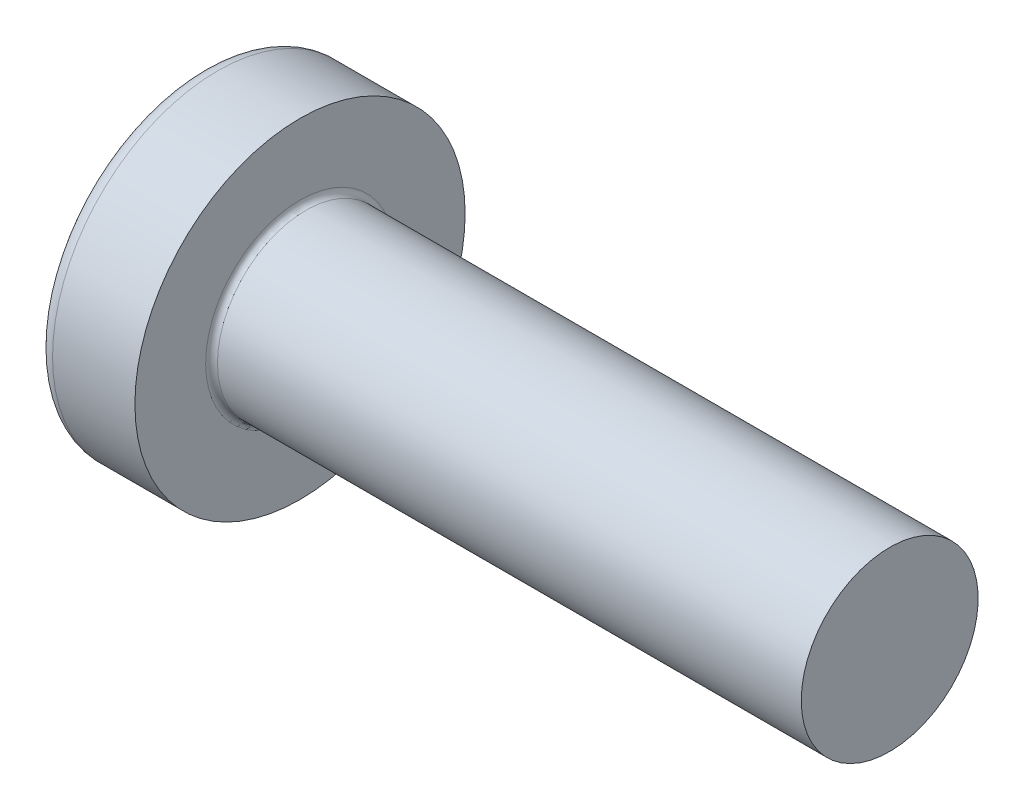
from build123d import *

# Parameters (mm, degrees)
FILLET1_R    = 0.1
SKETCH3_W    = 0.74
SKETCH3_H    = 2.8
SKETCH4_W    = 0.74
SKETCH4_H    = 1.054964432
RECPAT_COUNT = 2
RECPAT_ANGLE = 90


with BuildPart() as part:
    # BodySke → Base-Revolve (revolve)
    with BuildSketch(Plane.XY):
        with BuildLine():
            Line((2.4, 1.5), (2.4, 2.8))
            Line((2.4, 2.8), (1.003501533, 2.8))
            ThreePointArc((1.003501533, 2.8), (0.873295971, 2.76653015), (0.775371599, 2.674418605))
            ThreePointArc((0.775371599, 2.674418605), (0.197753546, 1.392274756), (0, 0))
            Line((0, 0), (12.4, 0))
            Line((12.4, 0), (12.4, 1.5))
            Line((12.4, 1.5), (2.4, 1.5))
        make_face()
    revolve(axis=Axis((-25.4, 0, 0), (1, 0, 0)))

    # Fillet1
    fillet1_edges = [part.edges().sort_by_distance(p)[0] for p in [
        (2.4, -1.5, 0),
    ]]
    fillet(fillet1_edges, radius=FILLET1_R)

    # Sketch3 → Recess section 0
    with BuildSketch(Plane(origin=(0, 0, 0), x_dir=(0, 0, -1), z_dir=(1, 0, 0))):
        Rectangle(SKETCH3_W, SKETCH3_H)
    # Sketch4 → Recess section 1
    with BuildSketch(Plane(origin=(1.75, 0, 0), x_dir=(0, 0, -1), z_dir=(1, 0, 0))):
        Rectangle(SKETCH4_W, SKETCH4_H)
    recess = loft(mode=Mode.SUBTRACT)

    # RecPat: Recess ×2 about axis
    recpat_axis = Axis((0, 0, 0), (1, 0, 0))
    for i in range(1, RECPAT_COUNT):
        add(recess.rotate(recpat_axis, i * RECPAT_ANGLE / (RECPAT_COUNT - 1)), mode=Mode.SUBTRACT)

    # RecCorSke → RecessCore (revolve, cut)
    with BuildSketch(Plane.XY):
        Polygon((0, 0), (0, 0.678371921), (1.75, 0.556), (1.930655351, 0), align=None)
    revolve(axis=Axis((-3.175, 0, 0), (1, 0, 0)), mode=Mode.SUBTRACT)


solid = part.part
